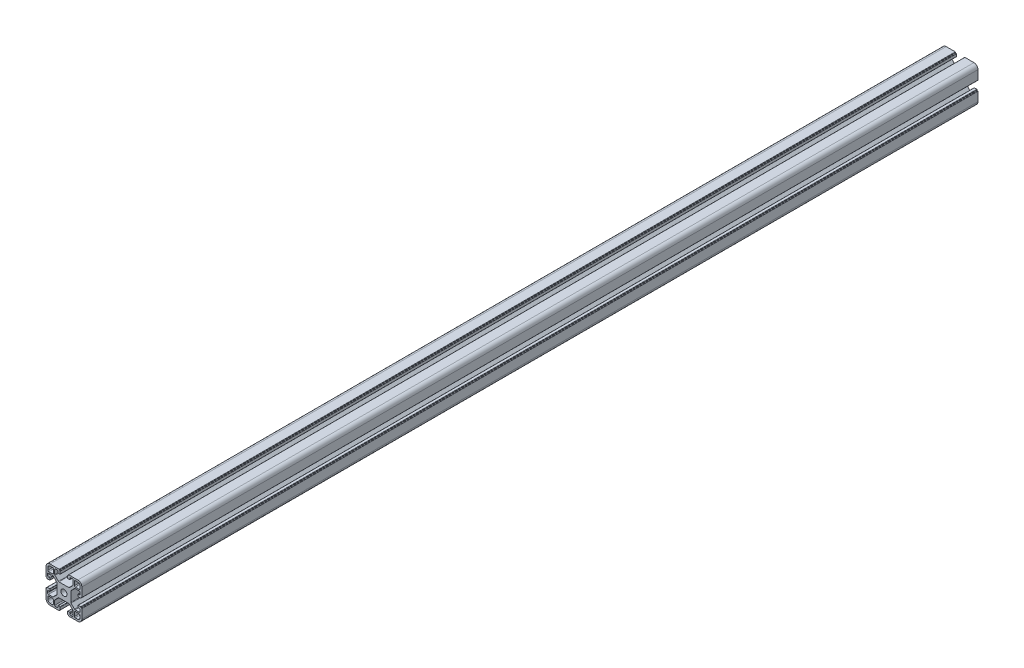
from build123d import *

# Parameters (mm, degrees)
SKETCH_1_R      = 3.4
EXTRUDE_1_DEPTH = 1000


with BuildPart() as part:
    # Эскиз1 → Бобышка-Вытянуть1 (new body)
    with BuildSketch(Plane.XY):
        with BuildLine():
            Line((-20, 10.25), (-20, 15.5))
            ThreePointArc((-20, 15.5), (-18.681980515, 18.681980515), (-15.5, 20))
            Line((-15.5, 20), (-10.25, 20))
            Line((-10.25, 20), (-5.4, 20))
            ThreePointArc((-5.4, 20), (-5.187867966, 19.912132034), (-5.1, 19.7))
            Line((-5.1, 19.7), (-5.1, 19.3))
            ThreePointArc((-5.1, 19.3), (-5.012132034, 19.087867966), (-4.8, 19))
            Line((-4.8, 19), (-4.4, 19))
            ThreePointArc((-4.4, 19), (-4.187867966, 18.912132034), (-4.1, 18.7))
            Line((-4.1, 18.7), (-4.1, 16))
            ThreePointArc((-4.1, 16), (-4.187867966, 15.787867966), (-4.4, 15.7))
            Line((-4.4, 15.7), (-6.3, 15.7))
            ThreePointArc((-6.3, 15.7), (-6.512132034, 15.787867966), (-6.6, 16))
            Line((-6.6, 16), (-6.6, 17.2))
            ThreePointArc((-6.6, 17.2), (-6.892893219, 17.907106781), (-7.6, 18.2))
            Line((-7.6, 18.2), (-9.25, 18.2))
            ThreePointArc((-9.25, 18.2), (-9.957106781, 17.907106781), (-10.25, 17.2))
            Line((-10.25, 17.2), (-10.25, 12.464213562))
            ThreePointArc((-10.25, 12.464213562), (-10.173879533, 12.08153013), (-9.957106781, 11.757106781))
            Line((-9.957106781, 11.757106781), (-6.192893219, 7.992893219))
            ThreePointArc((-6.192893219, 7.992893219), (-5.86846987, 7.776120467), (-5.485786438, 7.7))
            Line((-5.485786438, 7.7), (5.485786438, 7.7))
            ThreePointArc((5.485786438, 7.7), (5.86846987, 7.776120467), (6.192893219, 7.992893219))
            Line((6.192893219, 7.992893219), (9.957106781, 11.757106781))
            ThreePointArc((9.957106781, 11.757106781), (10.173879533, 12.08153013), (10.25, 12.464213562))
            Line((10.25, 12.464213562), (10.25, 17.2))
            ThreePointArc((10.25, 17.2), (9.957106781, 17.907106781), (9.25, 18.2))
            Line((9.25, 18.2), (7.6, 18.2))
            ThreePointArc((7.6, 18.2), (6.892893219, 17.907106781), (6.6, 17.2))
            Line((6.6, 17.2), (6.6, 16))
            ThreePointArc((6.6, 16), (6.512132034, 15.787867966), (6.3, 15.7))
            Line((6.3, 15.7), (4.4, 15.7))
            ThreePointArc((4.4, 15.7), (4.187867966, 15.787867966), (4.1, 16))
            Line((4.1, 16), (4.1, 18.7))
            ThreePointArc((4.1, 18.7), (4.187867966, 18.912132034), (4.4, 19))
            Line((4.4, 19), (4.8, 19))
            ThreePointArc((4.8, 19), (5.012132034, 19.087867966), (5.1, 19.3))
            Line((5.1, 19.3), (5.1, 19.7))
            ThreePointArc((5.1, 19.7), (5.187867966, 19.912132034), (5.4, 20))
            Line((5.4, 20), (10.25, 20))
            Line((10.25, 20), (15.5, 20))
            ThreePointArc((15.5, 20), (18.681980515, 18.681980515), (20, 15.5))
            Line((20, 15.5), (20, 10.25))
            Line((20, 10.25), (20, 5.4))
            ThreePointArc((20, 5.4), (19.912132034, 5.187867966), (19.7, 5.1))
            Line((19.7, 5.1), (19.3, 5.1))
            ThreePointArc((19.3, 5.1), (19.087867966, 5.012132034), (19, 4.8))
            Line((19, 4.8), (19, 4.4))
            ThreePointArc((19, 4.4), (18.912132034, 4.187867966), (18.7, 4.1))
            Line((18.7, 4.1), (16, 4.1))
            ThreePointArc((16, 4.1), (15.787867966, 4.187867966), (15.7, 4.4))
            Line((15.7, 4.4), (15.7, 6.3))
            ThreePointArc((15.7, 6.3), (15.787867966, 6.512132034), (16, 6.6))
            Line((16, 6.6), (17.2, 6.6))
            ThreePointArc((17.2, 6.6), (17.907106781, 6.892893219), (18.2, 7.6))
            Line((18.2, 7.6), (18.2, 9.25))
            ThreePointArc((18.2, 9.25), (17.907106781, 9.957106781), (17.2, 10.25))
            Line((17.2, 10.25), (12.464213562, 10.25))
            ThreePointArc((12.464213562, 10.25), (12.08153013, 10.173879533), (11.757106781, 9.957106781))
            Line((11.757106781, 9.957106781), (7.992893219, 6.192893219))
            ThreePointArc((7.992893219, 6.192893219), (7.776120467, 5.86846987), (7.7, 5.485786438))
            Line((7.7, 5.485786438), (7.7, -5.485786438))
            ThreePointArc((7.7, -5.485786438), (7.776120467, -5.86846987), (7.992893219, -6.192893219))
            Line((7.992893219, -6.192893219), (11.757106781, -9.957106781))
            ThreePointArc((11.757106781, -9.957106781), (12.08153013, -10.173879533), (12.464213562, -10.25))
            Line((12.464213562, -10.25), (17.2, -10.25))
            ThreePointArc((17.2, -10.25), (17.907106781, -9.957106781), (18.2, -9.25))
            Line((18.2, -9.25), (18.2, -7.6))
            ThreePointArc((18.2, -7.6), (17.907106781, -6.892893219), (17.2, -6.6))
            Line((17.2, -6.6), (16, -6.6))
            ThreePointArc((16, -6.6), (15.787867966, -6.512132034), (15.7, -6.3))
            Line((15.7, -6.3), (15.7, -4.4))
            ThreePointArc((15.7, -4.4), (15.787867966, -4.187867966), (16, -4.1))
            Line((16, -4.1), (18.7, -4.1))
            ThreePointArc((18.7, -4.1), (18.912132034, -4.187867966), (19, -4.4))
            Line((19, -4.4), (19, -4.8))
            ThreePointArc((19, -4.8), (19.087867966, -5.012132034), (19.3, -5.1))
            Line((19.3, -5.1), (19.7, -5.1))
            ThreePointArc((19.7, -5.1), (19.912132034, -5.187867966), (20, -5.4))
            Line((20, -5.4), (20, -10.25))
            Line((20, -10.25), (20, -15.5))
            ThreePointArc((20, -15.5), (18.681980515, -18.681980515), (15.5, -20))
            Line((15.5, -20), (10.25, -20))
            Line((10.25, -20), (5.4, -20))
            ThreePointArc((5.4, -20), (5.187867966, -19.912132034), (5.1, -19.7))
            Line((5.1, -19.7), (5.1, -19.3))
            ThreePointArc((5.1, -19.3), (5.012132034, -19.087867966), (4.8, -19))
            Line((4.8, -19), (4.4, -19))
            ThreePointArc((4.4, -19), (4.187867966, -18.912132034), (4.1, -18.7))
            Line((4.1, -18.7), (4.1, -16))
            ThreePointArc((4.1, -16), (4.187867966, -15.787867966), (4.4, -15.7))
            Line((4.4, -15.7), (6.3, -15.7))
            ThreePointArc((6.3, -15.7), (6.512132034, -15.787867966), (6.6, -16))
            Line((6.6, -16), (6.6, -17.2))
            ThreePointArc((6.6, -17.2), (6.892893219, -17.907106781), (7.6, -18.2))
            Line((7.6, -18.2), (9.25, -18.2))
            ThreePointArc((9.25, -18.2), (9.957106781, -17.907106781), (10.25, -17.2))
            Line((10.25, -17.2), (10.25, -12.464213562))
            ThreePointArc((10.25, -12.464213562), (10.173879533, -12.08153013), (9.957106781, -11.757106781))
            Line((9.957106781, -11.757106781), (6.192893219, -7.992893219))
            ThreePointArc((6.192893219, -7.992893219), (5.86846987, -7.776120467), (5.485786438, -7.7))
            Line((5.485786438, -7.7), (-5.485786438, -7.7))
            ThreePointArc((-5.485786438, -7.7), (-5.86846987, -7.776120467), (-6.192893219, -7.992893219))
            Line((-6.192893219, -7.992893219), (-9.957106781, -11.757106781))
            ThreePointArc((-9.957106781, -11.757106781), (-10.173879533, -12.08153013), (-10.25, -12.464213562))
            Line((-10.25, -12.464213562), (-10.25, -17.2))
            ThreePointArc((-10.25, -17.2), (-9.957106781, -17.907106781), (-9.25, -18.2))
            Line((-9.25, -18.2), (-7.6, -18.2))
            ThreePointArc((-7.6, -18.2), (-6.892893219, -17.907106781), (-6.6, -17.2))
            Line((-6.6, -17.2), (-6.6, -16))
            ThreePointArc((-6.6, -16), (-6.512132034, -15.787867966), (-6.3, -15.7))
            Line((-6.3, -15.7), (-4.4, -15.7))
            ThreePointArc((-4.4, -15.7), (-4.187867966, -15.787867966), (-4.1, -16))
            Line((-4.1, -16), (-4.1, -18.7))
            ThreePointArc((-4.1, -18.7), (-4.187867966, -18.912132034), (-4.4, -19))
            Line((-4.4, -19), (-4.8, -19))
            ThreePointArc((-4.8, -19), (-5.012132034, -19.087867966), (-5.1, -19.3))
            Line((-5.1, -19.3), (-5.1, -19.7))
            ThreePointArc((-5.1, -19.7), (-5.187867966, -19.912132034), (-5.4, -20))
            Line((-5.4, -20), (-10.25, -20))
            Line((-10.25, -20), (-15.5, -20))
            ThreePointArc((-15.5, -20), (-18.681980515, -18.681980515), (-20, -15.5))
            Line((-20, -15.5), (-20, -10.25))
            Line((-20, -10.25), (-20, -5.4))
            ThreePointArc((-20, -5.4), (-19.912132034, -5.187867966), (-19.7, -5.1))
            Line((-19.7, -5.1), (-19.3, -5.1))
            ThreePointArc((-19.3, -5.1), (-19.087867966, -5.012132034), (-19, -4.8))
            Line((-19, -4.8), (-19, -4.4))
            ThreePointArc((-19, -4.4), (-18.912132034, -4.187867966), (-18.7, -4.1))
            Line((-18.7, -4.1), (-16, -4.1))
            ThreePointArc((-16, -4.1), (-15.787867966, -4.187867966), (-15.7, -4.4))
            Line((-15.7, -4.4), (-15.7, -6.3))
            ThreePointArc((-15.7, -6.3), (-15.787867966, -6.512132034), (-16, -6.6))
            Line((-16, -6.6), (-17.2, -6.6))
            ThreePointArc((-17.2, -6.6), (-17.907106781, -6.892893219), (-18.2, -7.6))
            Line((-18.2, -7.6), (-18.2, -9.25))
            ThreePointArc((-18.2, -9.25), (-17.907106781, -9.957106781), (-17.2, -10.25))
            Line((-17.2, -10.25), (-12.464213562, -10.25))
            ThreePointArc((-12.464213562, -10.25), (-12.08153013, -10.173879533), (-11.757106781, -9.957106781))
            Line((-11.757106781, -9.957106781), (-7.992893219, -6.192893219))
            ThreePointArc((-7.992893219, -6.192893219), (-7.776120467, -5.86846987), (-7.7, -5.485786438))
            Line((-7.7, -5.485786438), (-7.7, 5.485786438))
            ThreePointArc((-7.7, 5.485786438), (-7.776120467, 5.86846987), (-7.992893219, 6.192893219))
            Line((-7.992893219, 6.192893219), (-11.757106781, 9.957106781))
            ThreePointArc((-11.757106781, 9.957106781), (-12.08153013, 10.173879533), (-12.464213562, 10.25))
            Line((-12.464213562, 10.25), (-17.2, 10.25))
            ThreePointArc((-17.2, 10.25), (-17.907106781, 9.957106781), (-18.2, 9.25))
            Line((-18.2, 9.25), (-18.2, 7.6))
            ThreePointArc((-18.2, 7.6), (-17.907106781, 6.892893219), (-17.2, 6.6))
            Line((-17.2, 6.6), (-16, 6.6))
            ThreePointArc((-16, 6.6), (-15.787867966, 6.512132034), (-15.7, 6.3))
            Line((-15.7, 6.3), (-15.7, 4.4))
            ThreePointArc((-15.7, 4.4), (-15.787867966, 4.187867966), (-16, 4.1))
            Line((-16, 4.1), (-18.7, 4.1))
            ThreePointArc((-18.7, 4.1), (-18.912132034, 4.187867966), (-19, 4.4))
            Line((-19, 4.4), (-19, 4.8))
            ThreePointArc((-19, 4.8), (-19.087867966, 5.012132034), (-19.3, 5.1))
            Line((-19.3, 5.1), (-19.7, 5.1))
            ThreePointArc((-19.7, 5.1), (-19.912132034, 5.187867966), (-20, 5.4))
            Line((-20, 5.4), (-20, 10.25))
        make_face()
        Circle(SKETCH_1_R, mode=Mode.SUBTRACT)
        with BuildLine():
            Line((-12.8, 11.8), (-17, 11.8))
            ThreePointArc((-17, 11.8), (-17.707106781, 12.092893219), (-18, 12.8))
            Line((-18, 12.8), (-18, 15.5))
            ThreePointArc((-18, 15.5), (-17.267766953, 17.267766953), (-15.5, 18))
            Line((-15.5, 18), (-12.8, 18))
            ThreePointArc((-12.8, 18), (-12.092893219, 17.707106781), (-11.8, 17))
            Line((-11.8, 17), (-11.8, 12.8))
            ThreePointArc((-11.8, 12.8), (-12.092893219, 12.092893219), (-12.8, 11.8))
        make_face(mode=Mode.SUBTRACT)
        with BuildLine():
            Line((11.8, 12.8), (11.8, 17))
            ThreePointArc((11.8, 17), (12.092893219, 17.707106781), (12.8, 18))
            Line((12.8, 18), (15.5, 18))
            ThreePointArc((15.5, 18), (17.267766953, 17.267766953), (18, 15.5))
            Line((18, 15.5), (18, 12.8))
            ThreePointArc((18, 12.8), (17.707106781, 12.092893219), (17, 11.8))
            Line((17, 11.8), (12.8, 11.8))
            ThreePointArc((12.8, 11.8), (12.092893219, 12.092893219), (11.8, 12.8))
        make_face(mode=Mode.SUBTRACT)
        with BuildLine():
            Line((12.8, -11.8), (17, -11.8))
            ThreePointArc((17, -11.8), (17.707106781, -12.092893219), (18, -12.8))
            Line((18, -12.8), (18, -15.5))
            ThreePointArc((18, -15.5), (17.267766953, -17.267766953), (15.5, -18))
            Line((15.5, -18), (12.8, -18))
            ThreePointArc((12.8, -18), (12.092893219, -17.707106781), (11.8, -17))
            Line((11.8, -17), (11.8, -12.8))
            ThreePointArc((11.8, -12.8), (12.092893219, -12.092893219), (12.8, -11.8))
        make_face(mode=Mode.SUBTRACT)
        with BuildLine():
            Line((-11.8, -12.8), (-11.8, -17))
            ThreePointArc((-11.8, -17), (-12.092893219, -17.707106781), (-12.8, -18))
            Line((-12.8, -18), (-15.5, -18))
            ThreePointArc((-15.5, -18), (-17.267766953, -17.267766953), (-18, -15.5))
            Line((-18, -15.5), (-18, -12.8))
            ThreePointArc((-18, -12.8), (-17.707106781, -12.092893219), (-17, -11.8))
            Line((-17, -11.8), (-12.8, -11.8))
            ThreePointArc((-12.8, -11.8), (-12.092893219, -12.092893219), (-11.8, -12.8))
        make_face(mode=Mode.SUBTRACT)
    extrude(amount=EXTRUDE_1_DEPTH)


solid = part.part
